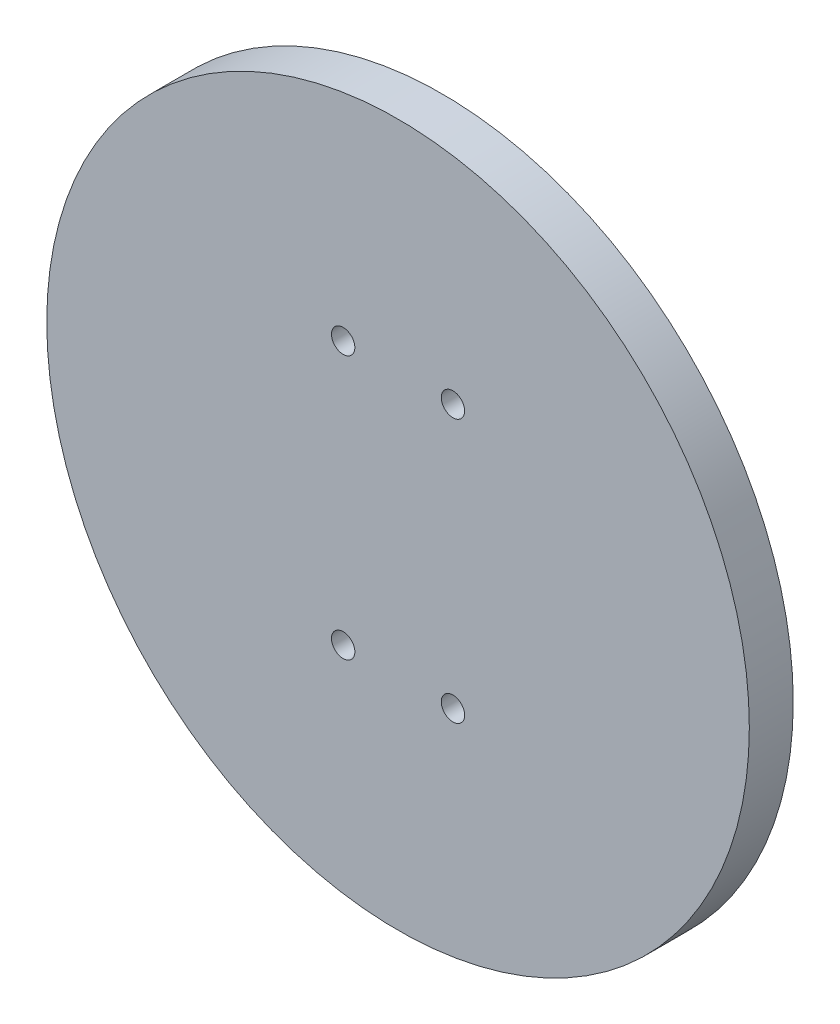
from build123d import *

# Parameters (mm, degrees)
SKETCH1_R                                           = 101.6
BOSS_EXTRUDE1_DEPTH                                 = 12.7
CSK_FOR_1_4_FLAT_HEAD_MACHINE_SCREW_100_D           = 6.7564
CSK_FOR_1_4_FLAT_HEAD_MACHINE_SCREW_100_DEPTH       = 25.4
CSK_FOR_1_4_FLAT_HEAD_MACHINE_SCREW_100_CSINK_D     = 12.8778
CSK_FOR_1_4_FLAT_HEAD_MACHINE_SCREW_100_CSINK_ANGLE = 100
CSK_FOR_1_4_FLAT_HEAD_MACHINE_SCREW_100_TIP         = 2.029827343


with BuildPart() as part:
    # Sketch1 → Boss-Extrude1 (new body)
    with BuildSketch(Plane.XY):
        Circle(SKETCH1_R)
    extrude(amount=BOSS_EXTRUDE1_DEPTH)

    # CSK for 1/4 Flat Head Machine Screw (100)1
    with Locations(Plane(origin=(0, 0, 0), x_dir=(-1, 0, 0), z_dir=(0, 0, -1))):
        with Locations((-15.875, -38.1), (-15.875, 38.1), (15.875, 38.1), (15.875, -38.1)):
            CounterSinkHole(CSK_FOR_1_4_FLAT_HEAD_MACHINE_SCREW_100_D / 2, CSK_FOR_1_4_FLAT_HEAD_MACHINE_SCREW_100_CSINK_D / 2, depth=CSK_FOR_1_4_FLAT_HEAD_MACHINE_SCREW_100_DEPTH, counter_sink_angle=CSK_FOR_1_4_FLAT_HEAD_MACHINE_SCREW_100_CSINK_ANGLE)
            with Locations((0, 0, -(CSK_FOR_1_4_FLAT_HEAD_MACHINE_SCREW_100_DEPTH + CSK_FOR_1_4_FLAT_HEAD_MACHINE_SCREW_100_TIP / 2))):  # 118° drill point
                Cone(0, CSK_FOR_1_4_FLAT_HEAD_MACHINE_SCREW_100_D / 2, CSK_FOR_1_4_FLAT_HEAD_MACHINE_SCREW_100_TIP, mode=Mode.SUBTRACT)


solid = part.part
